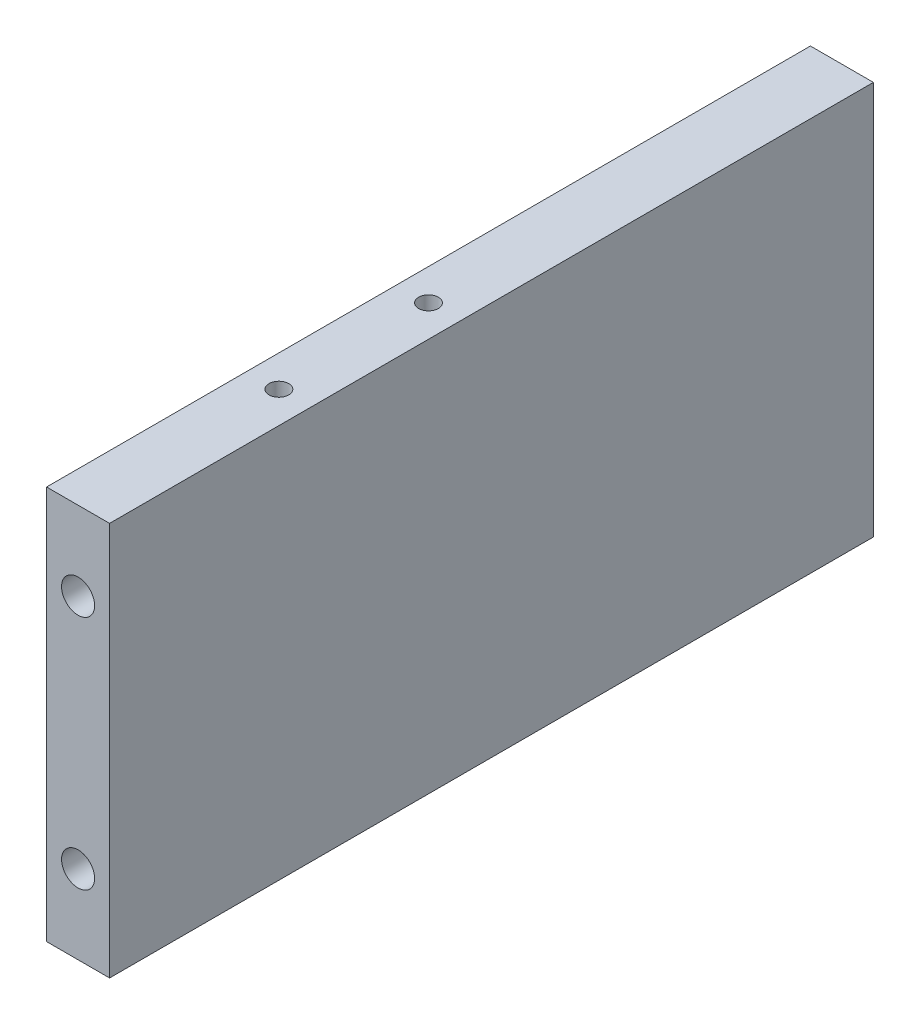
from build123d import *

# Parameters (mm, degrees)
SKETCH_1_W                  = 8
SKETCH_1_H                  = 50
EXTRUDE_1_DEPTH             = 97
HOLE_WIZARD_M5_2_AT_2_COUNT = 2
HOLE_WIZARD_M5_2_AT_2_PITCH = 30
HOLE_WIZARD_M3_1_D          = 2.5
HOLE_WIZARD_M3_1_DEPTH      = 7.5
HOLE_WIZARD_M3_1_TIP        = 0.751075774


with BuildPart() as part:
    # 草图1 → 凸台-拉伸1 (new body)
    with BuildSketch(Plane.XY):
        with Locations((4, 25)):
            Rectangle(SKETCH_1_W, SKETCH_1_H)
    extrude(amount=EXTRUDE_1_DEPTH)

    # 草图6 → M5 螺纹孔2 (revolve, cut)
    with BuildSketch(Plane(origin=(4, 40, 0), x_dir=(0, 1, 0), z_dir=(1, 0, 0))):
        Polygon((0, 0), (0, 13.6618073), (2.1, 12.4), (2.1, 0), align=None)
    hole_wizard_m5_2 = revolve(axis=Axis((4, 40, -6.35), (0, 0, 1)), mode=Mode.SUBTRACT)

    # M5 螺纹孔2 at 2: M5 螺纹孔2 ×2
    with Locations(*[(0, -i * HOLE_WIZARD_M5_2_AT_2_PITCH, 0) for i in range(1, HOLE_WIZARD_M5_2_AT_2_COUNT)]):
        add(hole_wizard_m5_2, mode=Mode.SUBTRACT)

    # 镜向1: M5 螺纹孔2 across plane
    add(hole_wizard_m5_2.mirror(Plane(origin=(0, 0, 48.5), x_dir=(1, 0, 0), z_dir=(0, 0, -1))), mode=Mode.SUBTRACT)

    # 镜向1 copy 1 sketch → 镜向1 copy 1 (revolve, cut)
    with BuildSketch(Plane(origin=(4, 10, 97), x_dir=(0, 1, 0), z_dir=(1, 0, 0))):
        Polygon((0, 0), (0, -13.6618073), (2.1, -12.4), (2.1, 0), align=None)
    revolve(axis=Axis((4, 10, 103.35), (0, 0, 1)), mode=Mode.SUBTRACT)

    # M3 螺纹孔1
    with Locations(Plane(origin=(0, 50, 0), x_dir=(1, 0, 0), z_dir=(0, 1, 0))):
        with Locations((4, -71.5), (4, -52.5)):
            Hole(HOLE_WIZARD_M3_1_D / 2, depth=HOLE_WIZARD_M3_1_DEPTH)
            with Locations((0, 0, -(HOLE_WIZARD_M3_1_DEPTH + HOLE_WIZARD_M3_1_TIP / 2))):  # 118° drill point
                Cone(0, HOLE_WIZARD_M3_1_D / 2, HOLE_WIZARD_M3_1_TIP, mode=Mode.SUBTRACT)


solid = part.part
